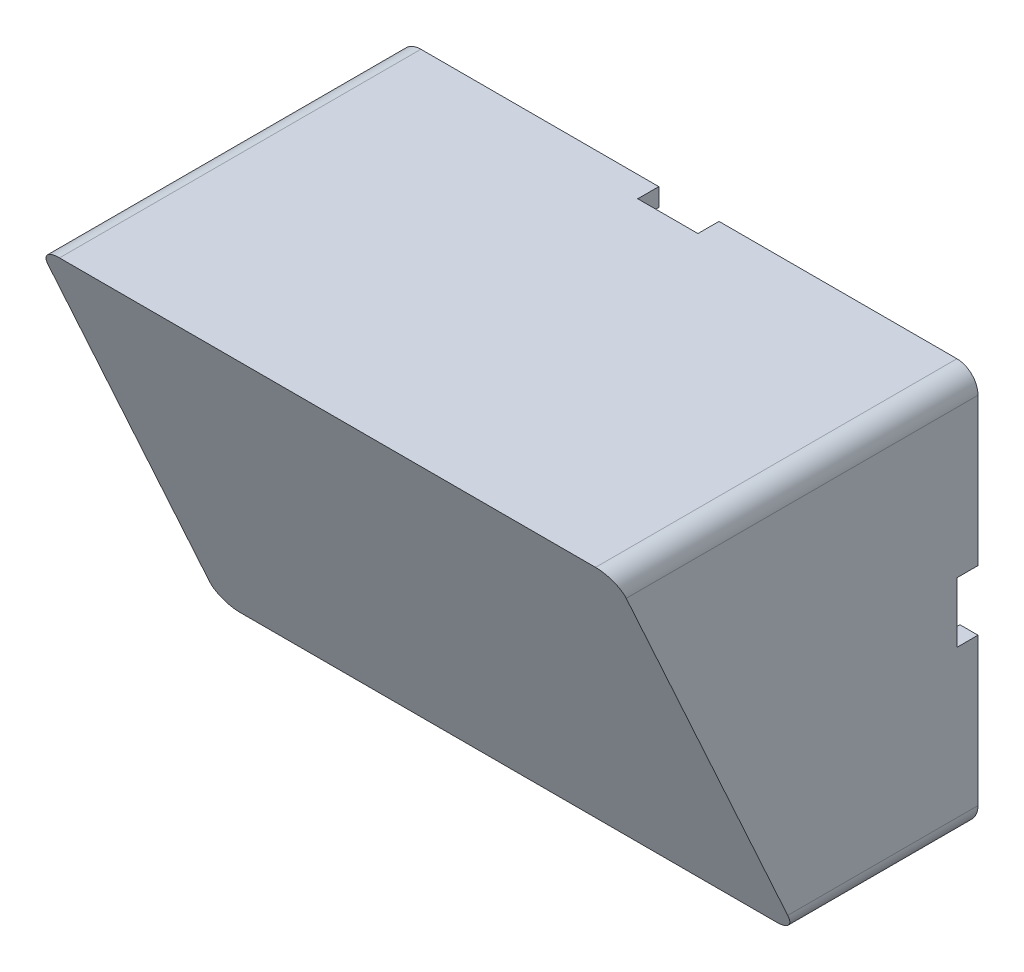
from build123d import *

# Parameters (mm, degrees)
CROQUIS1_W              = 96
CROQUIS1_H              = 66
SALIENTE_EXTRUIR1_DEPTH = 60
CORTAR_EXTRUIR1_DEPTH   = 100
VACIADO1_T              = -3
CROQUIS3_W              = 3
CROQUIS3_H              = 5
CROQUIS3_W_2            = 5
CROQUIS3_H_2            = 3
CROQUIS3_W_3            = 10
CROQUIS3_H_3            = 10
CORTAR_EXTRUIR2_DEPTH   = 3.5
REDONDEO1_R             = 3.5


with BuildPart() as part:
    # Croquis1 → Saliente-Extruir1 (new body)
    with BuildSketch(Plane.XY):
        with Locations((48, 33)):
            Rectangle(CROQUIS1_W, CROQUIS1_H)
    extrude(amount=SALIENTE_EXTRUIR1_DEPTH)

    # Croquis2 → Cortar-Extruir1 (cut)
    with BuildSketch(Plane(origin=(96, 0, 0), x_dir=(0, 0, -1), z_dir=(1, 0, 0))):
        Polygon((-60, 66), (-30, 0), (-60, 0), align=None)
    extrude(amount=-CORTAR_EXTRUIR1_DEPTH, mode=Mode.SUBTRACT)

    # Vaciado1
    vaciado1_openings = [part.faces().sort_by_distance(p)[0] for p in [
        (48, 33, 0),
    ]]
    offset(amount=VACIADO1_T, openings=vaciado1_openings, kind=Kind.INTERSECTION)

    # Croquis3 → Cortar-Extruir2 (cut)
    with BuildSketch(Plane(origin=(0, 0, 0), x_dir=(-1, 0, 0), z_dir=(0, 0, -1))):
        with Locations((-1.5, 35.5)):
            Rectangle(CROQUIS3_W, CROQUIS3_H)
        with Locations((-1.5, 30.5)):
            Rectangle(CROQUIS3_W, CROQUIS3_H)
        with Locations((-45.5, 64.5)):
            Rectangle(CROQUIS3_W_2, CROQUIS3_H_2)
        with Locations((-50.5, 64.5)):
            Rectangle(CROQUIS3_W_2, CROQUIS3_H_2)
        with Locations((-48, 1.5)):
            Rectangle(CROQUIS3_W_3, CROQUIS3_H_2)
        with Locations((-94.5, 33)):
            Rectangle(CROQUIS3_W, CROQUIS3_H_3)
    extrude(amount=-CORTAR_EXTRUIR2_DEPTH, mode=Mode.SUBTRACT)

    # Redondeo1
    redondeo1_edges = [part.edges().sort_by_distance(p)[0] for p in [
        (96, 0, 15),
        (0, 0, 15),
        (0, 66, 30),
        (96, 66, 30),
    ]]
    fillet(redondeo1_edges, radius=REDONDEO1_R)


solid = part.part
